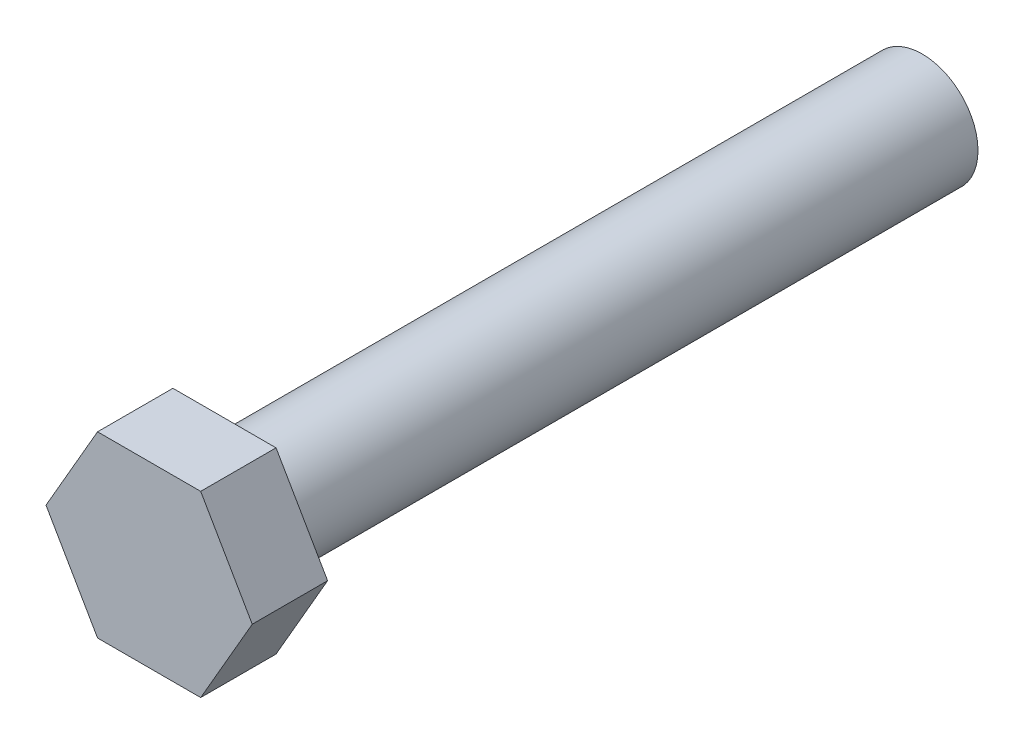
from build123d import *

# Parameters (mm, degrees)
SKETCH1_R      = 4
EXTRUDE1_DEPTH = 50
EXTRUDE2_DEPTH = 5.4


with BuildPart() as part:
    # Sketch1 → Extrude1 (new body)
    with BuildSketch(Plane.XY):
        Circle(SKETCH1_R)
    extrude(amount=EXTRUDE1_DEPTH)

    # Sketch2 → Extrude2 (add)
    with BuildSketch(Plane.XY.offset(50)):
        Polygon((7.390083446, 0), (3.695041723, 6.4), (-3.695041723, 6.4), (-7.390083446, 0), (-3.695041723, -6.4), (3.695041723, -6.4), align=None)
    extrude(amount=EXTRUDE2_DEPTH)


solid = part.part
